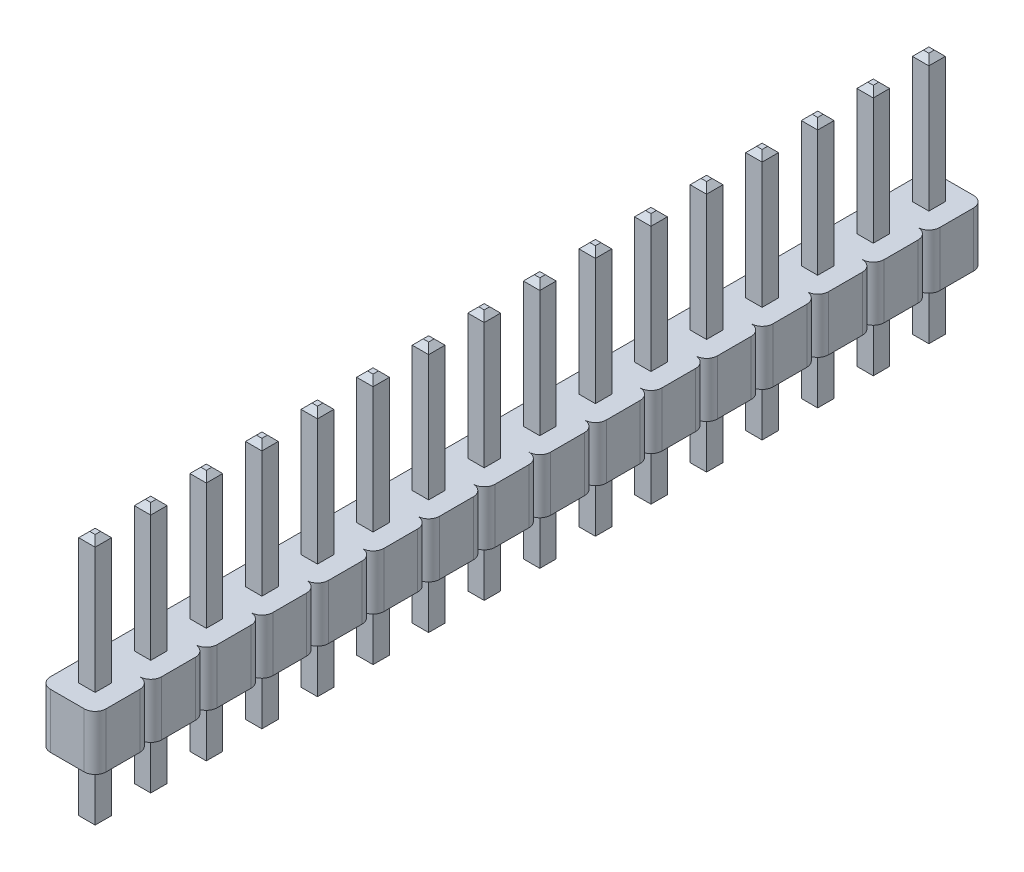
from build123d import *

# Parameters (mm, degrees)
BOSS_EXTRUDE1_DEPTH        = 2.5
LPATTERN1_COUNT            = 16
LPATTERN1_PITCH            = 2.54
BOSS_EXTRUDE2_START        = -3
SKETCH2_W                  = 0.75
SKETCH2_H                  = 0.75
BOSS_EXTRUDE2_DEPTH        = 11.5
CHAMFER1_SIZE              = 0.25
LPATTERN2_COUNT            = 16
LPATTERN2_PITCH            = 2.54
CHAMFER1_OF_LPATTERN2_SIZE = 0.25


with BuildPart() as part:
    # Sketch1 → Boss-Extrude1 (new body)
    with BuildSketch(Plane(origin=(0, 0, 0), x_dir=(-1, 0, 0), z_dir=(0, 1, 0))):
        with BuildLine():
            Line((-0.77, 1.27), (0.77, 1.27))
            ThreePointArc((0.77, 1.27), (1.123553391, 1.123553391), (1.27, 0.77))
            Line((1.27, 0.77), (1.27, -0.77))
            ThreePointArc((1.27, -0.77), (1.123553391, -1.123553391), (0.77, -1.27))
            Line((0.77, -1.27), (-0.77, -1.27))
            ThreePointArc((-0.77, -1.27), (-1.123553391, -1.123553391), (-1.27, -0.77))
            Line((-1.27, -0.77), (-1.27, 0.77))
            ThreePointArc((-1.27, 0.77), (-1.123553391, 1.123553391), (-0.77, 1.27))
        make_face()
    boss_extrude1 = extrude(amount=BOSS_EXTRUDE1_DEPTH)

    # LPattern1: Boss-Extrude1 ×16
    with Locations(*[(0, 0, i * LPATTERN1_PITCH) for i in range(1, LPATTERN1_COUNT)]):
        add(boss_extrude1)

    # Sketch2 → Boss-Extrude2 (add)
    with BuildSketch(Plane(origin=(0, 0, 0), x_dir=(-1, 0, 0), z_dir=(0, 1, 0)).offset(BOSS_EXTRUDE2_START)):
        Rectangle(SKETCH2_W, SKETCH2_H)
    boss_extrude2 = extrude(amount=BOSS_EXTRUDE2_DEPTH)

    # Chamfer1
    chamfer1_edges = [part.edges().sort_by_distance(p)[0] for p in [
        (0, -3, 0.375),
        (-0.375, -3, 0),
        (0.375, -3, 0),
        (0, -3, -0.375),
        (0, 8.5, 0.375),
        (-0.375, 8.5, 0),
        (0, 8.5, -0.375),
        (0.375, 8.5, 0),
    ]]
    chamfer(chamfer1_edges, length=CHAMFER1_SIZE)

    # LPattern2: Boss-Extrude2 ×16
    with Locations(*[(0, 0, i * LPATTERN2_PITCH) for i in range(1, LPATTERN2_COUNT)]):
        add(boss_extrude2)

    # Chamfer1 of LPattern2
    chamfer1_of_lpattern2_edges = [part.edges().sort_by_distance(p)[0] for p in [
        (0, -3, 2.915),
        (-0.375, -3, 2.54),
        (0.375, -3, 2.54),
        (0, -3, 2.165),
        (0, 8.5, 2.915),
        (-0.375, 8.5, 2.54),
        (0, 8.5, 2.165),
        (0.375, 8.5, 2.54),
        (0, -3, 5.455),
        (-0.375, -3, 5.08),
        (0.375, -3, 5.08),
        (0, -3, 4.705),
        (0, 8.5, 5.455),
        (-0.375, 8.5, 5.08),
        (0, 8.5, 4.705),
        (0.375, 8.5, 5.08),
        (0, -3, 7.995),
        (-0.375, -3, 7.62),
        (0.375, -3, 7.62),
        (0, -3, 7.245),
        (0, 8.5, 7.995),
        (-0.375, 8.5, 7.62),
        (0, 8.5, 7.245),
        (0.375, 8.5, 7.62),
        (0, -3, 10.535),
        (-0.375, -3, 10.16),
        (0.375, -3, 10.16),
        (0, -3, 9.785),
        (0, 8.5, 10.535),
        (-0.375, 8.5, 10.16),
        (0, 8.5, 9.785),
        (0.375, 8.5, 10.16),
        (0, -3, 13.075),
        (-0.375, -3, 12.7),
        (0.375, -3, 12.7),
        (0, -3, 12.325),
        (0, 8.5, 13.075),
        (-0.375, 8.5, 12.7),
        (0, 8.5, 12.325),
        (0.375, 8.5, 12.7),
        (0, -3, 15.615),
        (-0.375, -3, 15.24),
        (0.375, -3, 15.24),
        (0, -3, 14.865),
        (0, 8.5, 15.615),
        (-0.375, 8.5, 15.24),
        (0, 8.5, 14.865),
        (0.375, 8.5, 15.24),
        (0, -3, 18.155),
        (-0.375, -3, 17.78),
        (0.375, -3, 17.78),
        (0, -3, 17.405),
        (0, 8.5, 18.155),
        (-0.375, 8.5, 17.78),
        (0, 8.5, 17.405),
        (0.375, 8.5, 17.78),
        (0, -3, 20.695),
        (-0.375, -3, 20.32),
        (0.375, -3, 20.32),
        (0, -3, 19.945),
        (0, 8.5, 20.695),
        (-0.375, 8.5, 20.32),
        (0, 8.5, 19.945),
        (0.375, 8.5, 20.32),
        (0, -3, 23.235),
        (-0.375, -3, 22.86),
        (0.375, -3, 22.86),
        (0, -3, 22.485),
        (0, 8.5, 23.235),
        (-0.375, 8.5, 22.86),
        (0, 8.5, 22.485),
        (0.375, 8.5, 22.86),
        (0, -3, 25.775),
        (-0.375, -3, 25.4),
        (0.375, -3, 25.4),
        (0, -3, 25.025),
        (0, 8.5, 25.775),
        (-0.375, 8.5, 25.4),
        (0, 8.5, 25.025),
        (0.375, 8.5, 25.4),
        (0, -3, 28.315),
        (-0.375, -3, 27.94),
        (0.375, -3, 27.94),
        (0, -3, 27.565),
        (0, 8.5, 28.315),
        (-0.375, 8.5, 27.94),
        (0, 8.5, 27.565),
        (0.375, 8.5, 27.94),
        (0, -3, 30.855),
        (-0.375, -3, 30.48),
        (0.375, -3, 30.48),
        (0, -3, 30.105),
        (0, 8.5, 30.855),
        (-0.375, 8.5, 30.48),
        (0, 8.5, 30.105),
        (0.375, 8.5, 30.48),
        (0, -3, 33.395),
        (-0.375, -3, 33.02),
        (0.375, -3, 33.02),
        (0, -3, 32.645),
        (0, 8.5, 33.395),
        (-0.375, 8.5, 33.02),
        (0, 8.5, 32.645),
        (0.375, 8.5, 33.02),
        (0, -3, 35.935),
        (-0.375, -3, 35.56),
        (0.375, -3, 35.56),
        (0, -3, 35.185),
        (0, 8.5, 35.935),
        (-0.375, 8.5, 35.56),
        (0, 8.5, 35.185),
        (0.375, 8.5, 35.56),
        (0, -3, 38.475),
        (-0.375, -3, 38.1),
        (0.375, -3, 38.1),
        (0, -3, 37.725),
        (0, 8.5, 38.475),
        (-0.375, 8.5, 38.1),
        (0, 8.5, 37.725),
        (0.375, 8.5, 38.1),
    ]]
    chamfer(chamfer1_of_lpattern2_edges, length=CHAMFER1_OF_LPATTERN2_SIZE)


solid = part.part
